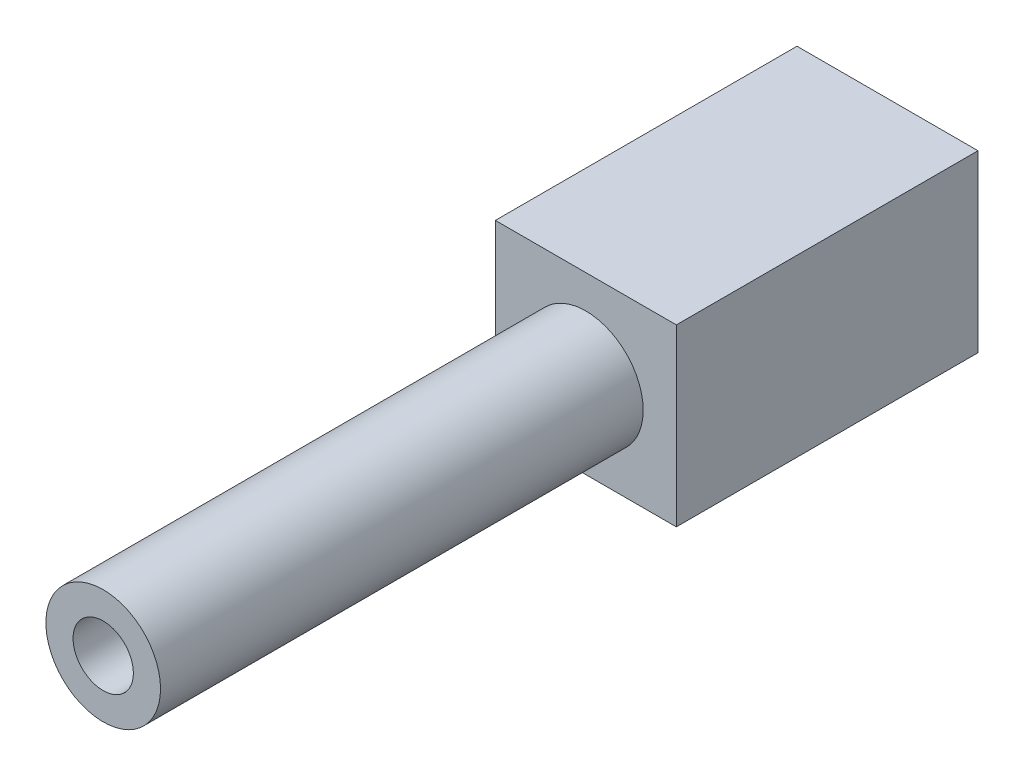
from build123d import *

# Parameters (mm, degrees)
SKETCH_1_R      = 1.9
SKETCH_1_R_2    = 1
EXTRUDE_1_DEPTH = 16
SKETCH_2_W      = 6
SKETCH_2_H      = 5.8
EXTRUDE_2_DEPTH = 10


with BuildPart() as part:
    # Эскиз1 → Бобышка-Вытянуть1 (new body)
    with BuildSketch(Plane.XY):
        Circle(SKETCH_1_R)
        Circle(SKETCH_1_R_2, mode=Mode.SUBTRACT)
    extrude(amount=EXTRUDE_1_DEPTH)

    # Эскиз2 → Бобышка-Вытянуть2 (add)
    with BuildSketch(Plane.XY):
        with Locations((0, 0.1)):
            Rectangle(SKETCH_2_W, SKETCH_2_H)
    extrude(amount=-EXTRUDE_2_DEPTH)


solid = part.part
